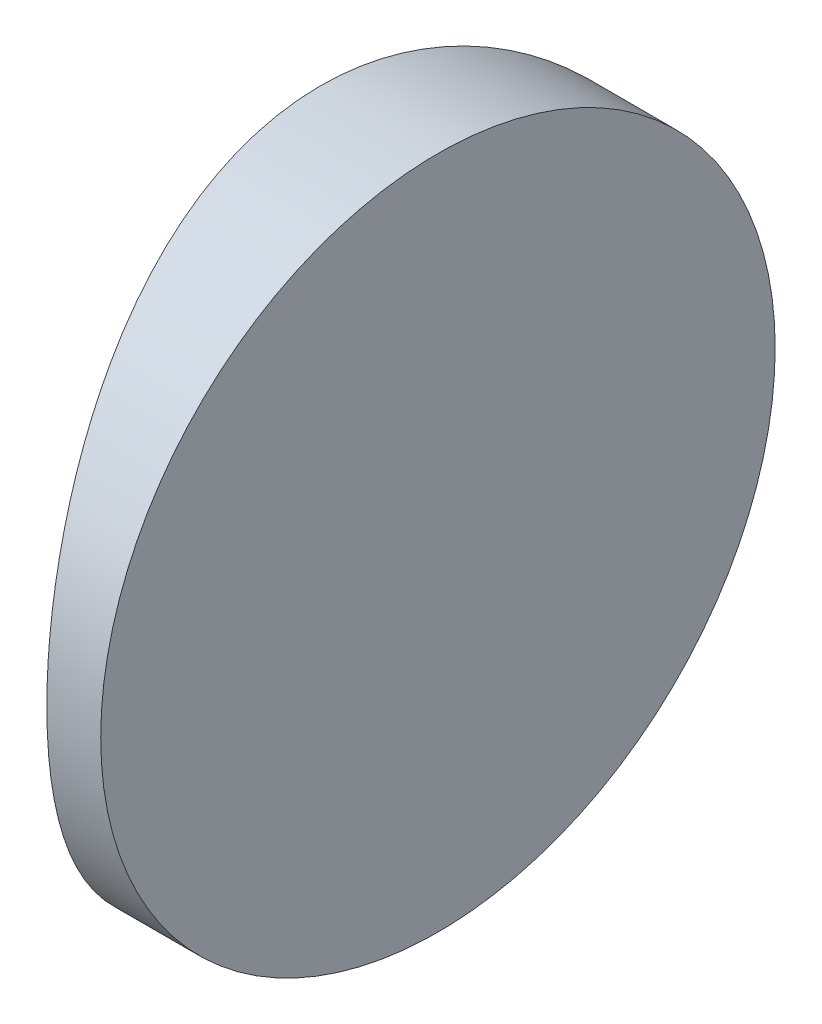
from build123d import *

# Parameters (mm, degrees)
EXTRUDE_1_DEPTH     = 25
CUT_EXTRUDE_8_DEPTH = 12.7


with BuildPart() as part:
    # 草图1 → 凸台-拉伸1 (new body)
    with BuildSketch(Plane(origin=(0, 0, 0), x_dir=(1, 0, 0), z_dir=(0, 1, 0))):
        with BuildLine():
            Line((-27.682618625, 12.5), (-25.684795665, 12.5))
            Line((-25.684795665, 12.5), (-25.684795665, -12.5))
            Line((-25.684795665, -12.5), (-27.682618625, -12.5))
            ThreePointArc((-27.682618625, -12.5), (-30.034795665, 0), (-27.682618625, 12.5))
        make_face()
    extrude(amount=EXTRUDE_1_DEPTH)

    # 草图2 → 切除-拉伸8 (cut)
    with BuildSketch(Plane(origin=(-25.684795665, 0, 0), x_dir=(0, 0, -1), z_dir=(1, 0, 0))):
        with BuildLine():
            Line((-12.5, 25), (-12.5, 12.5))
            ThreePointArc((-12.5, 12.5), (-8.838834765, 21.338834765), (0, 25))
            Line((0, 25), (-12.5, 25))
        make_face()
        with BuildLine():
            ThreePointArc((0, 25), (8.838834765, 21.338834765), (12.5, 12.5))
            Line((12.5, 12.5), (12.5, 25))
            Line((12.5, 25), (0, 25))
        make_face()
        with BuildLine():
            ThreePointArc((12.5, 12.5), (8.838834765, 3.661165235), (0, 0))
            Line((0, 0), (12.5, 0))
            Line((12.5, 0), (12.5, 12.5))
        make_face()
        with BuildLine():
            Line((-12.5, 12.5), (-12.5, 0))
            Line((-12.5, 0), (0, 0))
            ThreePointArc((0, 0), (-8.838834765, 3.661165235), (-12.5, 12.5))
        make_face()
    extrude(amount=-CUT_EXTRUDE_8_DEPTH, mode=Mode.SUBTRACT)


solid = part.part
